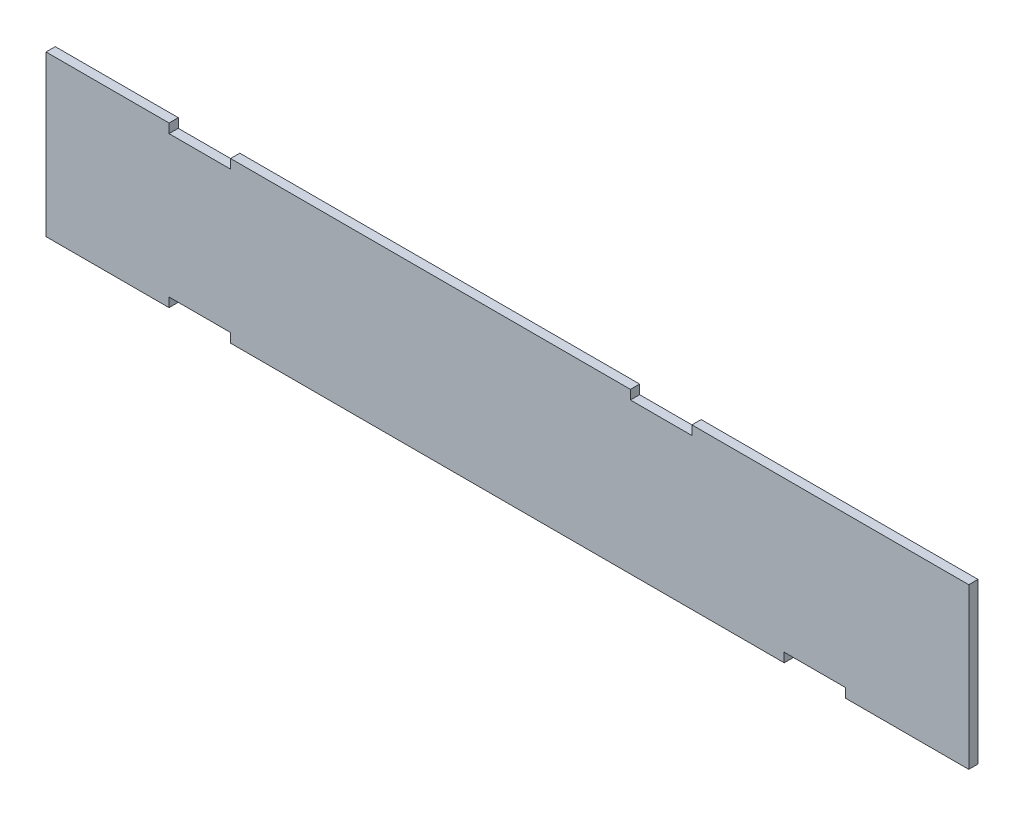
from build123d import *

# Parameters (mm, degrees)
SKETCH1_W           = 300
SKETCH1_H           = 52
BOSS_EXTRUDE2_DEPTH = 3
SKETCH2_W           = 20
SKETCH2_H           = 3
CUT_EXTRUDE1_DEPTH  = 10
SKETCH3_W           = 20
SKETCH3_H           = 3
CUT_EXTRUDE4_DEPTH  = 10
SKETCH4_W           = 20
SKETCH4_H           = 3
CUT_EXTRUDE5_DEPTH  = 10


with BuildPart() as part:
    # Sketch1 → Boss-Extrude2 (new body)
    with BuildSketch(Plane.XY):
        Rectangle(SKETCH1_W, SKETCH1_H)
    extrude(amount=BOSS_EXTRUDE2_DEPTH)

    # Sketch2 → Cut-Extrude1 (cut)
    with BuildSketch(Plane.XY.offset(3)):
        with Locations((-100, 24.5)):
            Rectangle(SKETCH2_W, SKETCH2_H)
    extrude(amount=-CUT_EXTRUDE1_DEPTH, mode=Mode.SUBTRACT)

    # Sketch3 → Cut-Extrude4 (cut)
    with BuildSketch(Plane.XY.offset(3)):
        with Locations((-100, -24.5)):
            Rectangle(SKETCH3_W, SKETCH3_H)
        with Locations((100, -24.5)):
            Rectangle(SKETCH3_W, SKETCH3_H)
    extrude(amount=-CUT_EXTRUDE4_DEPTH, mode=Mode.SUBTRACT)

    # Sketch4 → Cut-Extrude5 (cut)
    with BuildSketch(Plane.XY.offset(3)):
        with Locations((50, 24.5)):
            Rectangle(SKETCH4_W, SKETCH4_H)
    extrude(amount=-CUT_EXTRUDE5_DEPTH, mode=Mode.SUBTRACT)


solid = part.part
